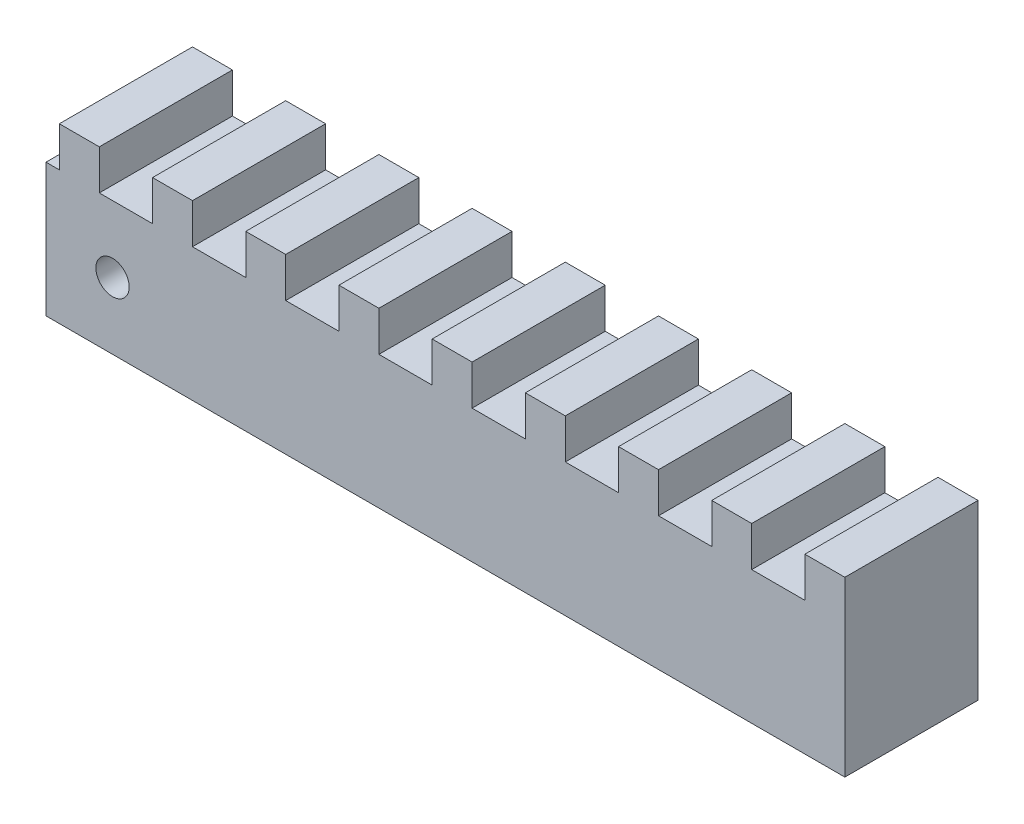
from build123d import *

# Parameters (mm, degrees)
SKETCH1_R        = 3.175
EXTRUSION2_DEPTH = 25.4


with BuildPart() as part:
    # Sketch1 → Extrusion2 (new body)
    with BuildSketch(Plane.XY):
        Polygon((0, 0), (152.4, 0), (152.4, 25.4), (152.4, 33.02), (144.767375471, 33.02), (144.767375471, 25.4), (134.626900767, 25.4), (134.626900767, 33.02), (127.006900767, 33.02), (127.006900767, 25.4), (116.846900767, 25.4), (116.846900767, 33.02), (109.226900767, 33.02), (109.226900767, 25.4), (99.066900767, 25.4), (99.066900767, 33.02), (91.446900767, 33.02), (91.446900767, 25.4), (81.286900767, 25.4), (81.286900767, 33.02), (73.666900767, 33.02), (73.666900767, 25.4), (63.506900767, 25.4), (63.506900767, 33.02), (55.886900767, 33.02), (55.886900767, 25.4), (45.726900767, 25.4), (45.726900767, 33.02), (38.106900767, 33.02), (38.106900767, 25.4), (27.946900767, 25.4), (27.946900767, 33.02), (20.326900767, 33.02), (20.326900767, 25.4), (10.166900767, 25.4), (10.166900767, 33.02), (2.546900767, 33.02), (2.546900767, 25.4), (0, 25.4), align=None)
        with Locations((12.694659047, 12.7)):
            Circle(SKETCH1_R, mode=Mode.SUBTRACT)
    extrude(amount=EXTRUSION2_DEPTH)


solid = part.part
